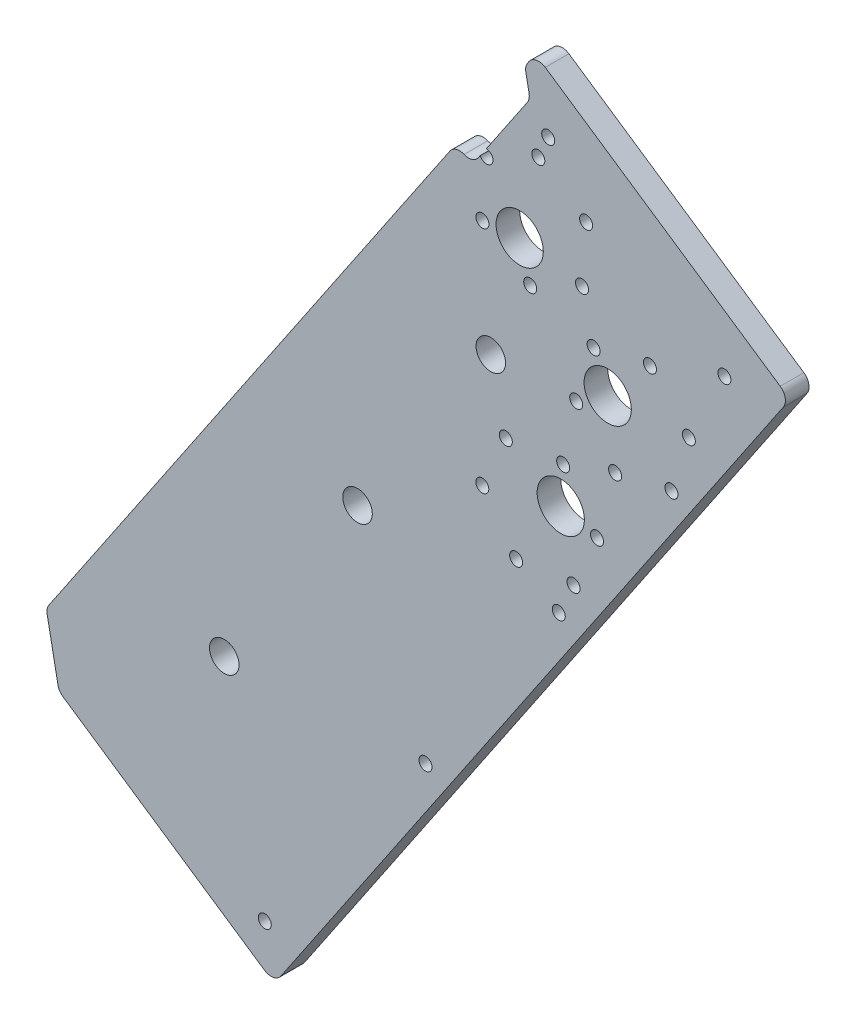
from build123d import *

# Parameters (mm, degrees)
BOSS_EXTRUDE2_DEPTH = 6.35
CUT_EXTRUDE1_DEPTH  = 7.3500001
BOSS_EXTRUDE3_DEPTH = 6.35
SKETCH10_R          = 3.96875
CUT_EXTRUDE2_DEPTH  = 7.35
SKETCH11_R          = 4.5
CUT_EXTRUDE4_DEPTH  = 7.35
BOSS_EXTRUDE4_DEPTH = 6.35
SKETCH13_R          = 1.75
CUT_EXTRUDE5_DEPTH  = 7.35
LPATTERN1_COUNT     = 2
LPATTERN1_PITCH     = 64
SKETCH15_R          = 1.75
CUT_EXTRUDE7_DEPTH  = 7.35
SKETCH16_R          = 1.75
CUT_EXTRUDE8_DEPTH  = 7.35
SKETCH17_R          = 1.75
CUT_EXTRUDE9_DEPTH  = 7.35
SKETCH18_R          = 1.75
SKETCH18_R_2        = 6.35
CUT_EXTRUDE10_DEPTH = 7.35
CUT_EXTRUDE11_DEPTH = 7.35
CUT_EXTRUDE12_DEPTH = 7.35
FILLET1_R           = 3.175
FILLET2_R           = 3.175


with BuildPart() as part:
    # Sketch6 → Boss-Extrude2 (new body)
    with BuildSketch(Plane.XY):
        with BuildLine():
            Line((-68.006850091, -76.67090114), (-109.486767671, -48.656527855))
            Line((-109.486767671, -48.656527855), (-118.371760678, -61.812230963))
            Line((-118.371760678, -61.812230963), (18.447551645, -154.216158235))
            Line((18.447551645, -154.216158235), (135.729459338, 19.43912279))
            Line((135.729459338, 19.43912279), (-1.089852986, 111.843050063))
            Line((-1.089852986, 111.843050063), (-73.946795643, 3.966284577))
            Line((-73.946795643, 3.966284577), (-56.624438948, -7.732749433))
            ThreePointArc((-56.624438948, -7.732749433), (-43.058385537, 37.577891571), (0, 57.15))
            ThreePointArc((0, 57.15), (56.404848571, 31.095576642), (70.829334649, -29.338471048))
            add(Edge.make_bspline(
                [(70.829334649, -29.338471048), (70.811686062, -29.418295928), (70.776015112, -29.578104383), (70.713320217, -29.85478305), (70.619021771, -30.262929245), (70.501052001, -30.762086912), (70.364034474, -31.322191481), (70.199318515, -31.970958926), (70.000453855, -32.723919765), (69.795103485, -33.469783355), (69.582015398, -34.214296028), (69.361377803, -34.956693289), (69.133257682, -35.696762218), (68.838782679, -36.61892651), (68.470566207, -37.720710028), (68.019498024, -38.998776477), (67.474836154, -40.448808619), (66.901337925, -41.887676852), (66.299328392, -43.31485223), (65.669141732, -44.729810424), (65.011119088, -46.132040323), (64.325609411, -47.52103904), (63.612968547, -48.896314904), (62.87355937, -50.257385735), (62.107751613, -51.603779381), (61.315921169, -52.935034173), (60.49845004, -54.250698756), (59.655726138, -55.550331897), (58.571247582, -57.154294757), (57.220953058, -59.045283389), (55.576035723, -61.200397094), (53.604026134, -63.590264702), (51.54329346, -65.904053004), (49.39728314, -68.138962994), (47.169496434, -70.29235602), (44.863486103, -72.361752995), (42.482847363, -74.344831806), (40.031215607, -76.239428526), (36.882516177, -78.494556171), (32.976808929, -81.016011003), (28.250788286, -83.68089187), (21.41551215, -86.919136497), (14.30829026, -89.526654921), (6.996956895, -91.488176442), (-0.451922312, -92.797413176), (-6.61686174, -93.456358442), (-12.81195397, -93.702029749), (-19.009644204, -93.537285056), (-25.183124422, -92.966685286), (-31.306438312, -91.996382122), (-36.598524037, -90.804323442), (-41.072542301, -89.543185606), (-44.752319298, -88.33589156), (-47.664184976, -87.27761875), (-50.541347258, -86.128353728), (-53.381128552, -84.889612663), (-56.180924218, -83.562977818), (-58.593536599, -82.326710176), (-60.633378351, -81.214215821), (-62.313751085, -80.252471782), (-63.646071553, -79.462491566), (-64.966093336, -78.652178853), (-66.222359154, -77.854259082), (-67.143044791, -77.250601571), (-67.736251212, -76.85365602), (-68.006850091, -76.67090114)],
                knots=[0.071020771, 0.071020771, 0.071020771, 0.071020771, 0.071020771, 0.072848477, 0.074676184, 0.07650389, 0.078331597, 0.08198701, 0.085642423, 0.089297836, 0.092953249, 0.096608662, 0.100264075, 0.103919488, 0.107574901, 0.114885727, 0.122196554, 0.12950738, 0.136818214, 0.144129048, 0.151439882, 0.158750716, 0.166061558, 0.173372401, 0.180683243, 0.187994085, 0.195304924, 0.202615763, 0.209926602, 0.217237441, 0.231859103, 0.246480766, 0.261102426, 0.275724085, 0.290345754, 0.304967424, 0.319589099, 0.334210774, 0.348832457, 0.36345414, 0.392697464, 0.421940789, 0.451184112, 0.506140643, 0.535383973, 0.564627303, 0.593870641, 0.623113979, 0.652357319, 0.68160066, 0.710843985, 0.740087309, 0.754708984, 0.769330659, 0.783952333, 0.798574008, 0.813195669, 0.82781733, 0.842438991, 0.849749821, 0.857060652, 0.86437149, 0.871682327, 0.878993165, 0.885158103, 0.885158103, 0.885158103, 0.885158103, 0.885158103], degree=4))
        make_face()
    extrude(amount=BOSS_EXTRUDE2_DEPTH)

    # Sketch8 → Cut-Extrude1 (cut, through all)
    with BuildSketch(Plane.XY.offset(6.35)):
        Polygon((-71.011229489, -93.798205788), (-53.378672597, -90.381637707), (-42.854110111, -97.489632113), (-39.43754203, -115.122189004), align=None)
    extrude(amount=-CUT_EXTRUDE1_DEPTH, mode=Mode.SUBTRACT)

    # Sketch9 → Boss-Extrude3 (add, through all)
    with BuildSketch(Plane.XY.offset(6.35)):
        Polygon((-1.089852986, 111.843050063), (-109.486767671, -48.656527855), (27.332544652, -141.060455127), (135.729459338, 19.43912279), align=None)
    extrude(amount=-BOSS_EXTRUDE3_DEPTH)

    # Sketch10 → Cut-Extrude2 (cut, through all)
    with BuildSketch(Plane.XY.offset(6.35)):
        with Locations((4.996496209, -84.796642912)):
            Circle(SKETCH10_R)
        with Locations((40.816310536, -31.759477627)):
            Circle(SKETCH10_R)
        with Locations((76.636124864, 21.277687659)):
            Circle(SKETCH10_R)
        with Locations((-45.295165913, -45.214466102)):
            Circle(SKETCH10_R)
    extrude(amount=-CUT_EXTRUDE2_DEPTH, mode=Mode.SUBTRACT)

    # Sketch11 → Cut-Extrude4 (cut, through all)
    with BuildSketch(Plane.XY.offset(6.35)):
        Circle(SKETCH11_R)
    extrude(amount=-CUT_EXTRUDE4_DEPTH, mode=Mode.SUBTRACT)

    # Sketch12 → Boss-Extrude4 (add, through all)
    with BuildSketch(Plane.XY.offset(6.35)):
        Polygon((135.729459338, 19.43912279), (67.319803176, 65.641086427), (88.643786393, 97.214773886), (157.053442554, 51.01281025), align=None)
    extrude(amount=-BOSS_EXTRUDE4_DEPTH)

    # Sketch13 → Cut-Extrude5 (cut, through all)
    with BuildSketch(Plane.XY.offset(6.35)):
        with Locations((94.899221836, -29.671127724)):
            Circle(SKETCH13_R)
    cut_extrude5 = extrude(amount=-CUT_EXTRUDE5_DEPTH, mode=Mode.SUBTRACT)

    # LPattern1: Cut-Extrude5 ×2
    with Locations(*[Vector(-0.559684599, -0.828705708, 0) * (i * LPATTERN1_PITCH) for i in range(1, LPATTERN1_COUNT)]):
        add(cut_extrude5, mode=Mode.SUBTRACT)

    # Sketch15 → Cut-Extrude7 (cut, through all)
    with BuildSketch(Plane.XY.offset(6.35)):
        with Locations((-105.147343009, -59.249804902)):
            Circle(SKETCH15_R)
        with Locations((15.885125585, -140.991740566)):
            Circle(SKETCH15_R)
        with Locations((1.472573075, 98.618632394)):
            Circle(SKETCH15_R)
    extrude(amount=-CUT_EXTRUDE7_DEPTH, mode=Mode.SUBTRACT)

    # Sketch16 → Cut-Extrude8 (cut, through all)
    with BuildSketch(Plane.XY.offset(6.35)):
        with Locations((92.060354474, 79.582216994)):
            Circle(SKETCH16_R)
        with Locations((139.420885662, 47.596242169)):
            Circle(SKETCH16_R)
    extrude(amount=-CUT_EXTRUDE8_DEPTH, mode=Mode.SUBTRACT)

    # Sketch17 → Cut-Extrude9 (cut, through all)
    with BuildSketch(Plane.XY.offset(6.35)):
        with Locations((-26.311406216, 17.769986014)):
            Circle(SKETCH17_R)
        with Locations((17.769986014, 26.311406216)):
            Circle(SKETCH17_R)
    extrude(amount=-CUT_EXTRUDE9_DEPTH, mode=Mode.SUBTRACT)

    # Sketch18 → Cut-Extrude10 (cut, through all)
    with BuildSketch(Plane.XY.offset(6.35)):
        with Locations((75.468896753, 66.798604333)):
            Circle(SKETCH18_R)
        with Locations((74.378499235, 51.337005669)):
            Circle(SKETCH18_R)
        with Locations((87.223437703, 42.661894386)):
            Circle(SKETCH18_R)
        with Locations((101.158773688, 49.448381768)):
            Circle(SKETCH18_R)
        with Locations((102.249171205, 64.909980432)):
            Circle(SKETCH18_R)
        with Locations((89.404232738, 73.585091715)):
            Circle(SKETCH18_R)
        with Locations((99.589076537, 21.914747078)):
            Circle(SKETCH18_R)
        with Locations((104.266720973, 36.692082512)):
            Circle(SKETCH18_R)
        with Locations((119.403091077, 40.029791318)):
            Circle(SKETCH18_R)
        with Locations((129.861816745, 28.59016469)):
            Circle(SKETCH18_R)
        with Locations((125.18417231, 13.812829255)):
            Circle(SKETCH18_R)
        with Locations((110.047802206, 10.47512045)):
            Circle(SKETCH18_R)
        with Locations((105.180381325, -7.122099496)):
            Circle(SKETCH18_R)
        with Locations((96.077150237, 5.423066257)):
            Circle(SKETCH18_R)
        with Locations((80.661102457, 3.812019754)):
            Circle(SKETCH18_R)
        with Locations((74.348285765, -10.344192501)):
            Circle(SKETCH18_R)
        with Locations((83.451516853, -22.889358254)):
            Circle(SKETCH18_R)
        with Locations((98.867564633, -21.278311751)):
            Circle(SKETCH18_R)
        with Locations((84.396043028, 52.322553097)):
            Circle(SKETCH18_R_2)
        with Locations((108.051811284, 27.364940468)):
            Circle(SKETCH18_R_2)
        with Locations((95.429892272, -4.622009378)):
            Circle(SKETCH18_R_2)
    extrude(amount=-CUT_EXTRUDE10_DEPTH, mode=Mode.SUBTRACT)

    # Sketch19 → Cut-Extrude11 (cut, through all)
    with BuildSketch(Plane.XY.offset(6.35)):
        Polygon((67.319803176, 65.641086427), (-1.089852986, 111.843050063), (-118.81528907, -62.468948176), (-50.405632909, -108.670911813), align=None)
    extrude(amount=-CUT_EXTRUDE11_DEPTH, mode=Mode.SUBTRACT)

    # Sketch20 → Cut-Extrude12 (cut, through all)
    with BuildSketch(Plane.XY.offset(6.35)):
        Polygon((85.800588631, 93.004948891), (87.167215863, 85.951926135), (71.529628171, 62.797888664), (67.319803176, 65.641086427), align=None)
    extrude(amount=-CUT_EXTRUDE12_DEPTH, mode=Mode.SUBTRACT)

    # Fillet1
    fillet1_edges = [part.edges().sort_by_distance(p)[0] for p in [
        (18.447551645, -154.216158235, 3.175),
        (87.167215863, 85.951926135, 3.175),
        (85.800588631, 93.004948891, 3.175),
        (71.529628171, 62.797888664, 3.175),
        (-39.43754203, -115.122189004, 3.175),
        (-42.854110111, -97.489632113, 3.175),
        (157.053442554, 51.01281025, 3.175),
        (88.643786393, 97.214773886, 3.175),
    ]]
    fillet(fillet1_edges, radius=FILLET1_R)

    # Fillet2
    fillet2_edges = [part.edges().sort_by_distance(p)[0] for p in [
        (67.319803176, 65.641086427, 3.175),
    ]]
    fillet(fillet2_edges, radius=FILLET2_R)


solid = part.part
